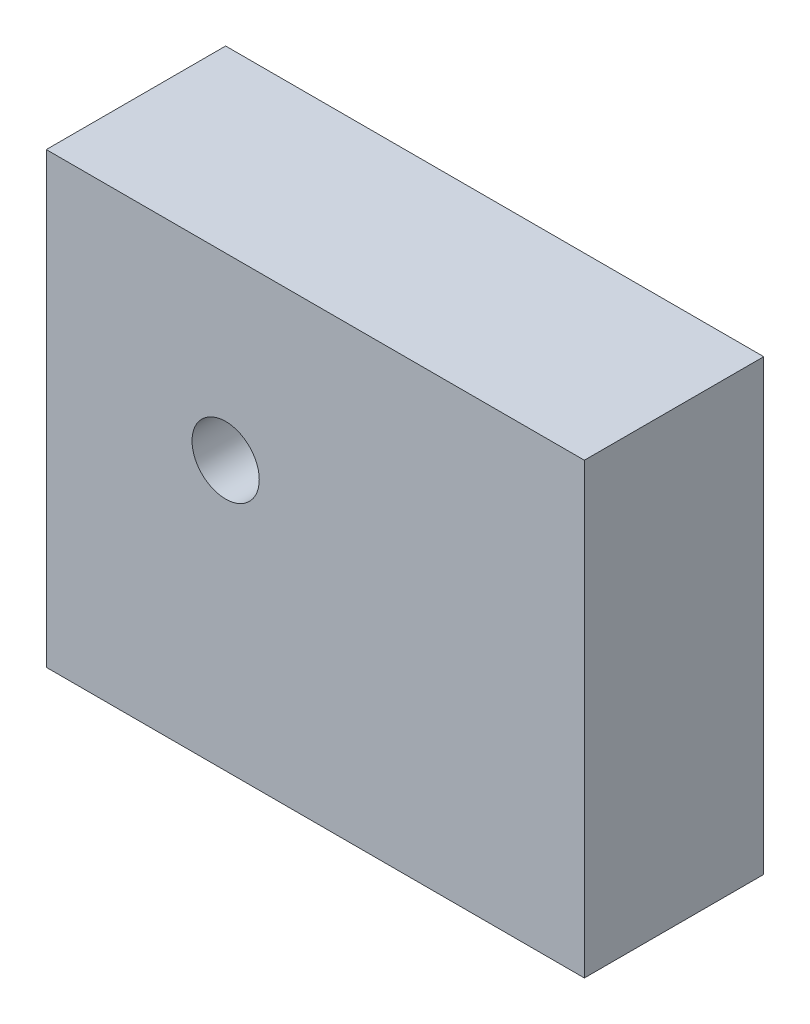
from build123d import *

# Parameters (mm, degrees)
SKETCH1_W           = 76.2
SKETCH1_H           = 63.5
SKETCH1_R           = 4.7625
BOSS_EXTRUDE1_DEPTH = 25.4


with BuildPart() as part:
    # Sketch1 → Boss-Extrude1 (new body)
    with BuildSketch(Plane.XY):
        with Locations((38.1, 31.75)):
            Rectangle(SKETCH1_W, SKETCH1_H)
        with Locations((25.4, 38.1)):
            Circle(SKETCH1_R, mode=Mode.SUBTRACT)
    extrude(amount=BOSS_EXTRUDE1_DEPTH)


solid = part.part
